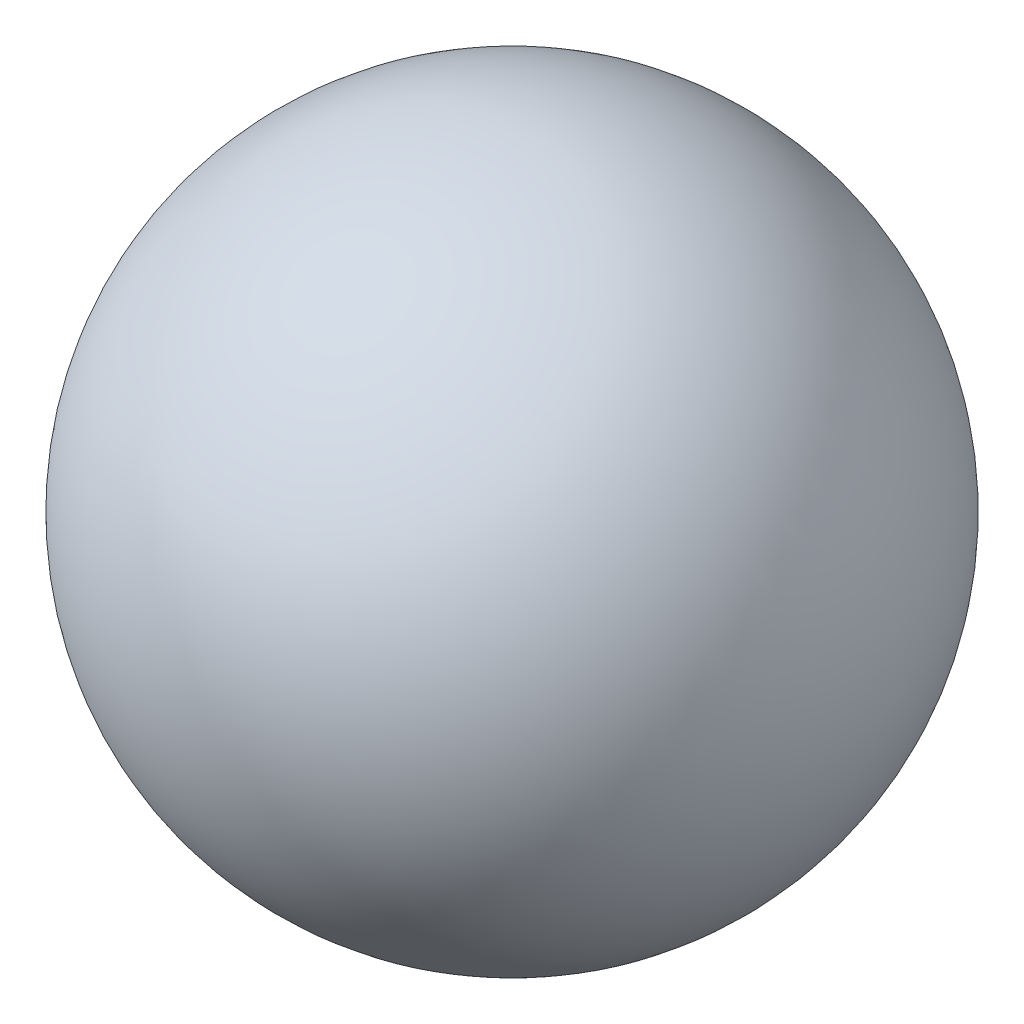
from build123d import *


with BuildPart() as part:
    # Sketch1 → Revolve3 (revolve)
    with BuildSketch(Plane.XY):
        with BuildLine():
            Line((0, 1.25), (0, -1.25))
            ThreePointArc((0, -1.25), (1.25, 0), (0, 1.25))
        make_face()
    revolve(axis=Axis((0, 2.693825656, 0), (0, -1, 0)))


solid = part.part
